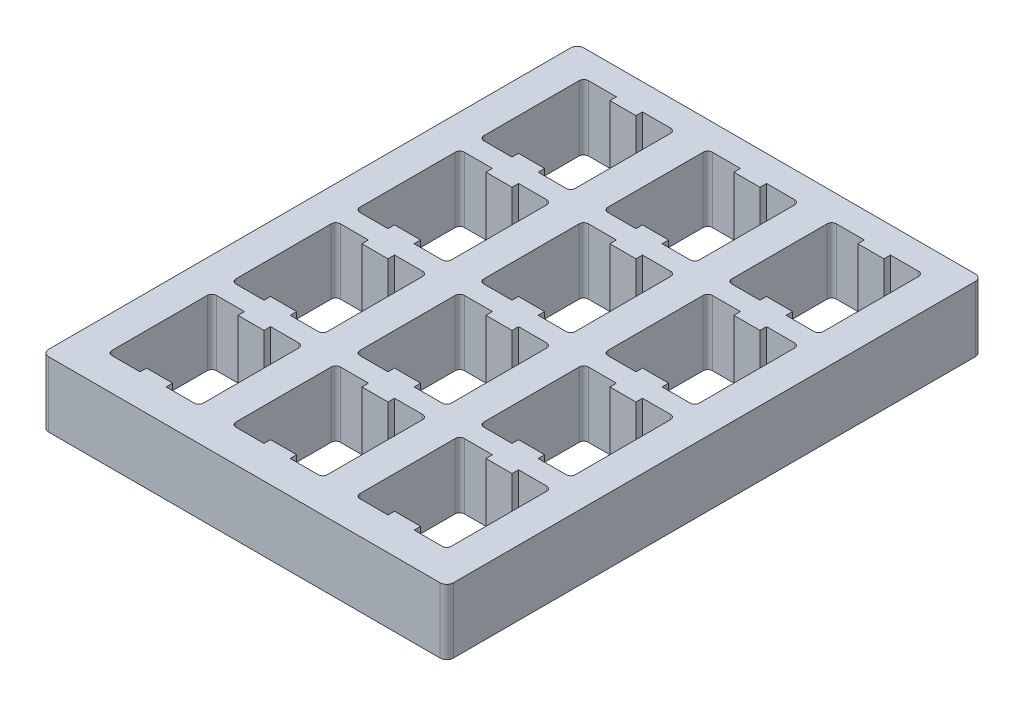
from build123d import *

# Parameters (mm, degrees)
SKETCH1_W              = 62
SKETCH1_H              = 82
BOSS_EXTRUDE1_DEPTH    = 10
FILLET1_R              = 1
CUT_EXTRUDE2_DEPTH     = 10
LPATTERN1_COUNT        = 4
LPATTERN1_PITCH        = 19
LPATTERN3_COUNT        = 2
LPATTERN3_PITCH        = 19
LPATTERN3_COPY_1_DEPTH = 10
LPATTERN3_COPY_2_DEPTH = 10
LPATTERN3_COPY_3_DEPTH = 10
LPATTERN4_COUNT        = 2
LPATTERN4_PITCH        = 19
LPATTERN4_COPY_1_DEPTH = 10
LPATTERN4_COPY_2_DEPTH = 10
LPATTERN4_COPY_3_DEPTH = 10


with BuildPart() as part:
    # Sketch1 → Boss-Extrude1 (new body)
    with BuildSketch(Plane(origin=(0, 0, 0), x_dir=(1, 0, 0), z_dir=(0, 1, 0))):
        Rectangle(SKETCH1_W, SKETCH1_H)
    extrude(amount=BOSS_EXTRUDE1_DEPTH)

    # Fillet1
    fillet1_edges = [part.edges().sort_by_distance(p)[0] for p in [
        (31, 5, 41),
        (-31, 5, 41),
        (-31, 5, -41),
        (31, 5, -41),
    ]]
    fillet(fillet1_edges, radius=FILLET1_R)

    # Sketch2 → Cut-Extrude2 (cut)
    with BuildSketch(Plane(origin=(0, 10, 0), x_dir=(1, 0, 0), z_dir=(0, 1, 0))):
        with BuildLine():
            Line((2, 21), (2, 22))
            Line((2, 22), (-2, 22))
            Line((-2, 22), (-2, 21))
            Line((-2, 21), (-6.3, 21))
            ThreePointArc((-6.3, 21), (-6.794974747, 21.205025253), (-7, 21.7))
            Line((-7, 21.7), (-7, 36.3))
            ThreePointArc((-7, 36.3), (-6.794974747, 36.794974747), (-6.3, 37))
            Line((-6.3, 37), (-2, 37))
            Line((-2, 37), (-2, 36))
            Line((-2, 36), (2, 36))
            Line((2, 36), (2, 37))
            Line((2, 37), (6.3, 37))
            ThreePointArc((6.3, 37), (6.794974747, 36.794974747), (7, 36.3))
            Line((7, 36.3), (7, 21.7))
            ThreePointArc((7, 21.7), (6.794974747, 21.205025253), (6.3, 21))
            Line((6.3, 21), (2, 21))
        make_face()
    cut_extrude2 = extrude(amount=-CUT_EXTRUDE2_DEPTH, mode=Mode.SUBTRACT)

    # LPattern1: Cut-Extrude2 ×4
    with Locations(*[(0, 0, i * LPATTERN1_PITCH) for i in range(1, LPATTERN1_COUNT)]):
        add(cut_extrude2, mode=Mode.SUBTRACT)

    # LPattern3: Cut-Extrude2 ×2
    with Locations(*[(-i * LPATTERN3_PITCH, 0, 0) for i in range(1, LPATTERN3_COUNT)]):
        add(cut_extrude2, mode=Mode.SUBTRACT)

    # LPattern3 copy 1 sketch → LPattern3 copy 1 (cut)
    with BuildSketch(Plane(origin=(-19, 10, 19), x_dir=(1, 0, 0), z_dir=(0, 1, 0))):
        with BuildLine():
            Line((2, 21), (2, 22))
            Line((2, 22), (-2, 22))
            Line((-2, 22), (-2, 21))
            Line((-2, 21), (-6.3, 21))
            ThreePointArc((-6.3, 21), (-6.794974747, 21.205025253), (-7, 21.7))
            Line((-7, 21.7), (-7, 36.3))
            ThreePointArc((-7, 36.3), (-6.794974747, 36.794974747), (-6.3, 37))
            Line((-6.3, 37), (-2, 37))
            Line((-2, 37), (-2, 36))
            Line((-2, 36), (2, 36))
            Line((2, 36), (2, 37))
            Line((2, 37), (6.3, 37))
            ThreePointArc((6.3, 37), (6.794974747, 36.794974747), (7, 36.3))
            Line((7, 36.3), (7, 21.7))
            ThreePointArc((7, 21.7), (6.794974747, 21.205025253), (6.3, 21))
            Line((6.3, 21), (2, 21))
        make_face()
    extrude(amount=-LPATTERN3_COPY_1_DEPTH, mode=Mode.SUBTRACT)

    # LPattern3 copy 2 sketch → LPattern3 copy 2 (cut)
    with BuildSketch(Plane(origin=(-19, 10, 38), x_dir=(1, 0, 0), z_dir=(0, 1, 0))):
        with BuildLine():
            Line((2, 21), (2, 22))
            Line((2, 22), (-2, 22))
            Line((-2, 22), (-2, 21))
            Line((-2, 21), (-6.3, 21))
            ThreePointArc((-6.3, 21), (-6.794974747, 21.205025253), (-7, 21.7))
            Line((-7, 21.7), (-7, 36.3))
            ThreePointArc((-7, 36.3), (-6.794974747, 36.794974747), (-6.3, 37))
            Line((-6.3, 37), (-2, 37))
            Line((-2, 37), (-2, 36))
            Line((-2, 36), (2, 36))
            Line((2, 36), (2, 37))
            Line((2, 37), (6.3, 37))
            ThreePointArc((6.3, 37), (6.794974747, 36.794974747), (7, 36.3))
            Line((7, 36.3), (7, 21.7))
            ThreePointArc((7, 21.7), (6.794974747, 21.205025253), (6.3, 21))
            Line((6.3, 21), (2, 21))
        make_face()
    extrude(amount=-LPATTERN3_COPY_2_DEPTH, mode=Mode.SUBTRACT)

    # LPattern3 copy 3 sketch → LPattern3 copy 3 (cut)
    with BuildSketch(Plane(origin=(-19, 10, 57), x_dir=(1, 0, 0), z_dir=(0, 1, 0))):
        with BuildLine():
            Line((2, 21), (2, 22))
            Line((2, 22), (-2, 22))
            Line((-2, 22), (-2, 21))
            Line((-2, 21), (-6.3, 21))
            ThreePointArc((-6.3, 21), (-6.794974747, 21.205025253), (-7, 21.7))
            Line((-7, 21.7), (-7, 36.3))
            ThreePointArc((-7, 36.3), (-6.794974747, 36.794974747), (-6.3, 37))
            Line((-6.3, 37), (-2, 37))
            Line((-2, 37), (-2, 36))
            Line((-2, 36), (2, 36))
            Line((2, 36), (2, 37))
            Line((2, 37), (6.3, 37))
            ThreePointArc((6.3, 37), (6.794974747, 36.794974747), (7, 36.3))
            Line((7, 36.3), (7, 21.7))
            ThreePointArc((7, 21.7), (6.794974747, 21.205025253), (6.3, 21))
            Line((6.3, 21), (2, 21))
        make_face()
    extrude(amount=-LPATTERN3_COPY_3_DEPTH, mode=Mode.SUBTRACT)

    # LPattern4: Cut-Extrude2 ×2
    with Locations(*[(i * LPATTERN4_PITCH, 0, 0) for i in range(1, LPATTERN4_COUNT)]):
        add(cut_extrude2, mode=Mode.SUBTRACT)

    # LPattern4 copy 1 sketch → LPattern4 copy 1 (cut)
    with BuildSketch(Plane(origin=(19, 10, 19), x_dir=(1, 0, 0), z_dir=(0, 1, 0))):
        with BuildLine():
            Line((2, 21), (2, 22))
            Line((2, 22), (-2, 22))
            Line((-2, 22), (-2, 21))
            Line((-2, 21), (-6.3, 21))
            ThreePointArc((-6.3, 21), (-6.794974747, 21.205025253), (-7, 21.7))
            Line((-7, 21.7), (-7, 36.3))
            ThreePointArc((-7, 36.3), (-6.794974747, 36.794974747), (-6.3, 37))
            Line((-6.3, 37), (-2, 37))
            Line((-2, 37), (-2, 36))
            Line((-2, 36), (2, 36))
            Line((2, 36), (2, 37))
            Line((2, 37), (6.3, 37))
            ThreePointArc((6.3, 37), (6.794974747, 36.794974747), (7, 36.3))
            Line((7, 36.3), (7, 21.7))
            ThreePointArc((7, 21.7), (6.794974747, 21.205025253), (6.3, 21))
            Line((6.3, 21), (2, 21))
        make_face()
    extrude(amount=-LPATTERN4_COPY_1_DEPTH, mode=Mode.SUBTRACT)

    # LPattern4 copy 2 sketch → LPattern4 copy 2 (cut)
    with BuildSketch(Plane(origin=(19, 10, 38), x_dir=(1, 0, 0), z_dir=(0, 1, 0))):
        with BuildLine():
            Line((2, 21), (2, 22))
            Line((2, 22), (-2, 22))
            Line((-2, 22), (-2, 21))
            Line((-2, 21), (-6.3, 21))
            ThreePointArc((-6.3, 21), (-6.794974747, 21.205025253), (-7, 21.7))
            Line((-7, 21.7), (-7, 36.3))
            ThreePointArc((-7, 36.3), (-6.794974747, 36.794974747), (-6.3, 37))
            Line((-6.3, 37), (-2, 37))
            Line((-2, 37), (-2, 36))
            Line((-2, 36), (2, 36))
            Line((2, 36), (2, 37))
            Line((2, 37), (6.3, 37))
            ThreePointArc((6.3, 37), (6.794974747, 36.794974747), (7, 36.3))
            Line((7, 36.3), (7, 21.7))
            ThreePointArc((7, 21.7), (6.794974747, 21.205025253), (6.3, 21))
            Line((6.3, 21), (2, 21))
        make_face()
    extrude(amount=-LPATTERN4_COPY_2_DEPTH, mode=Mode.SUBTRACT)

    # LPattern4 copy 3 sketch → LPattern4 copy 3 (cut)
    with BuildSketch(Plane(origin=(19, 10, 57), x_dir=(1, 0, 0), z_dir=(0, 1, 0))):
        with BuildLine():
            Line((2, 21), (2, 22))
            Line((2, 22), (-2, 22))
            Line((-2, 22), (-2, 21))
            Line((-2, 21), (-6.3, 21))
            ThreePointArc((-6.3, 21), (-6.794974747, 21.205025253), (-7, 21.7))
            Line((-7, 21.7), (-7, 36.3))
            ThreePointArc((-7, 36.3), (-6.794974747, 36.794974747), (-6.3, 37))
            Line((-6.3, 37), (-2, 37))
            Line((-2, 37), (-2, 36))
            Line((-2, 36), (2, 36))
            Line((2, 36), (2, 37))
            Line((2, 37), (6.3, 37))
            ThreePointArc((6.3, 37), (6.794974747, 36.794974747), (7, 36.3))
            Line((7, 36.3), (7, 21.7))
            ThreePointArc((7, 21.7), (6.794974747, 21.205025253), (6.3, 21))
            Line((6.3, 21), (2, 21))
        make_face()
    extrude(amount=-LPATTERN4_COPY_3_DEPTH, mode=Mode.SUBTRACT)


solid = part.part
